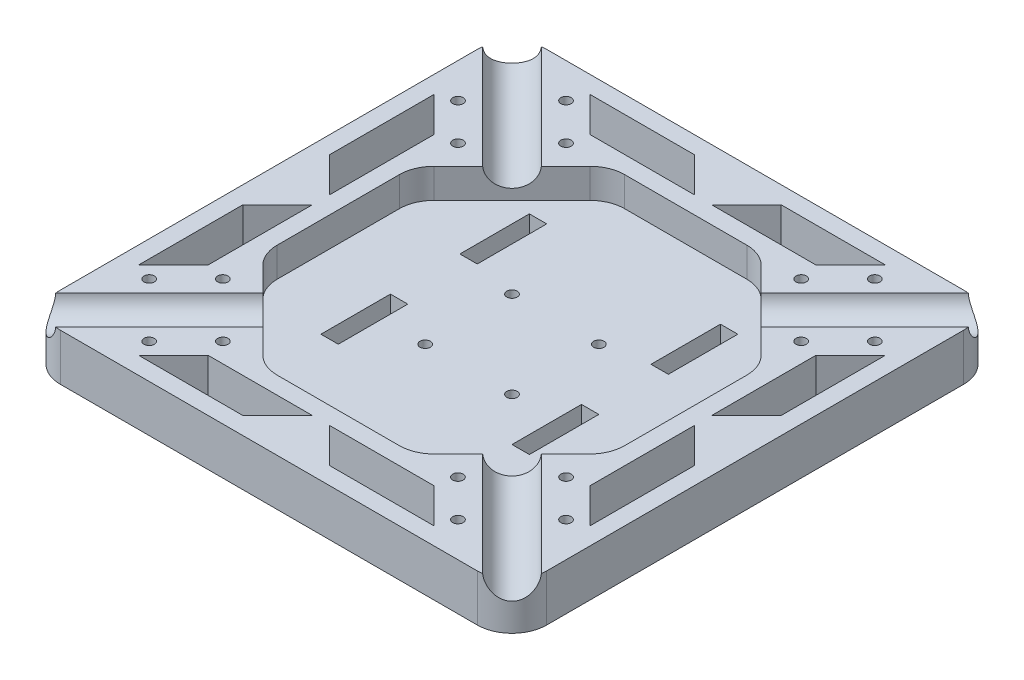
from build123d import *

# Parameters (mm, degrees)
ESQUISSE1_W                  = 140
ESQUISSE1_H                  = 140
ESQUISSE1_W_2                = 5
ESQUISSE1_H_2                = 20
BOSS_EXTRU_1_DEPTH           = 13.5
ENL_V_MAT_EXTRU_3_DEPTH      = 8.5
ENL_V_MAT_EXTRU_1_DEPTH      = 100
R_P_TITION_CIRCULAIRE1_COUNT = 2
R_P_TITION_CIRCULAIRE1_ANGLE = 90
CONG_1_R                     = 10
ESQUISSE3_R                  = 1.5
ENL_V_MAT_EXTRU_2_DEPTH      = 13.5


with BuildPart() as part:
    # Esquisse1 → Boss.-Extru.1 (new body)
    with BuildSketch(Plane(origin=(0, 0, 0), x_dir=(1, 0, 0), z_dir=(0, 1, 0))):
        Rectangle(ESQUISSE1_W, ESQUISSE1_H)
        with Locations((-27.5, 25)):
            Rectangle(ESQUISSE1_W_2, ESQUISSE1_H_2, mode=Mode.SUBTRACT)
        Polygon((65, 12.5), (55, 2.5), (55, 32.5), (65, 42.5), align=None, mode=Mode.SUBTRACT)
        Polygon((65, -12.5), (55, -2.5), (55, -32.5), (65, -42.5), align=None, mode=Mode.SUBTRACT)
        Polygon((12.5, -65), (2.5, -55), (32.5, -55), (42.5, -65), align=None, mode=Mode.SUBTRACT)
        Polygon((-12.5, -65), (-2.5, -55), (-32.5, -55), (-42.5, -65), align=None, mode=Mode.SUBTRACT)
        Polygon((-65, -12.5), (-55, -2.5), (-55, -32.5), (-65, -42.5), align=None, mode=Mode.SUBTRACT)
        Polygon((-65, 12.5), (-55, 2.5), (-55, 32.5), (-65, 42.5), align=None, mode=Mode.SUBTRACT)
        Polygon((-12.5, 65), (-2.5, 55), (-32.5, 55), (-42.5, 65), align=None, mode=Mode.SUBTRACT)
        Polygon((12.5, 65), (2.5, 55), (32.5, 55), (42.5, 65), align=None, mode=Mode.SUBTRACT)
        with Locations((-27.5, -15)):
            Rectangle(ESQUISSE1_W_2, ESQUISSE1_H_2, mode=Mode.SUBTRACT)
        with Locations((27.5, 25)):
            Rectangle(ESQUISSE1_W_2, ESQUISSE1_H_2, mode=Mode.SUBTRACT)
        with Locations((27.5, -15)):
            Rectangle(ESQUISSE1_W_2, ESQUISSE1_H_2, mode=Mode.SUBTRACT)
    extrude(amount=BOSS_EXTRU_1_DEPTH)

    # Esquisse4 → Enlèv. mat.-Extru.3 (cut)
    with BuildSketch(Plane(origin=(0, 13.5, 0), x_dir=(1, 0, 0), z_dir=(0, 1, 0))):
        Polygon((-21.715728753, -50), (21.715728753, -50), (50, -21.715728753), (50, 21.715728753), (21.715728753, 50), (-21.715728753, 50), (-50, 21.715728753), (-50, -21.715728753), align=None)
    extrude(amount=-ENL_V_MAT_EXTRU_3_DEPTH, mode=Mode.SUBTRACT)

    # Esquisse2 → Enlèv. mat.-Extru.1 (cut, symmetric)
    with BuildSketch(Plane(origin=(0, 0, 0), x_dir=(0.7071067811865475, 0, -0.7071067811865477), z_dir=(0.7071067811865477, 0, 0.7071067811865475))):
        with BuildLine():
            Line((-6, 14), (6, 14))
            ThreePointArc((6, 14), (0, 8), (-6, 14))
        make_face()
    enl_v_mat_extru_1 = extrude(amount=ENL_V_MAT_EXTRU_1_DEPTH, both=True, mode=Mode.SUBTRACT)

    # Répétition circulaire1: Enlèv. mat.-Extru.1 ×2 about axis
    r_p_tition_circulaire1_axis = Axis((0, -76.187687151, 0), (0, 1, 0))
    for i in range(1, R_P_TITION_CIRCULAIRE1_COUNT):
        add(enl_v_mat_extru_1.rotate(r_p_tition_circulaire1_axis, i * R_P_TITION_CIRCULAIRE1_ANGLE / (R_P_TITION_CIRCULAIRE1_COUNT - 1)), mode=Mode.SUBTRACT)

    # Congé1
    cong_1_edges = [part.edges().sort_by_distance(p)[0] for p in [
        (-70, 4, -70),
        (-70, 4, 70),
        (70, 4, -70),
        (70, 4, 70),
        (21.715728753, 9.25, -50),
        (50, 9.25, -21.715728753),
        (50, 9.25, 21.715728753),
        (21.715728753, 9.25, 50),
        (-21.715728753, 9.25, 50),
        (-50, 9.25, 21.715728753),
        (-21.715728753, 9.25, -50),
        (-50, 9.25, -21.715728753),
    ]]
    fillet(cong_1_edges, radius=CONG_1_R)

    # Esquisse3 → Enlèv. mat.-Extru.2 (cut)
    with BuildSketch(Plane(origin=(0, 13.5, 0), x_dir=(-1, 0, 0), z_dir=(0, 1, 0))):
        with Locations((44.443650814, 60)):
            Circle(ESQUISSE3_R)
        with Locations((60, 44.443650814)):
            Circle(ESQUISSE3_R)
        with Locations((60, -44.443650814)):
            Circle(ESQUISSE3_R)
        with Locations((44.443650814, -60)):
            Circle(ESQUISSE3_R)
        with Locations((-44.443650814, -60)):
            Circle(ESQUISSE3_R)
        with Locations((-60, -44.443650814)):
            Circle(ESQUISSE3_R)
        with Locations((-60, 44.443650814)):
            Circle(ESQUISSE3_R)
        with Locations((-44.443650814, 60)):
            Circle(ESQUISSE3_R)
        with Locations((49.393398282, 33.837049096)):
            Circle(ESQUISSE3_R)
        with Locations((33.837049096, 49.393398282)):
            Circle(ESQUISSE3_R)
        with Locations((33.837049096, -49.393398282)):
            Circle(ESQUISSE3_R)
        with Locations((49.393398282, -33.837049096)):
            Circle(ESQUISSE3_R)
        with Locations((-49.393398282, -33.837049096)):
            Circle(ESQUISSE3_R)
        with Locations((-33.837049096, -49.393398282)):
            Circle(ESQUISSE3_R)
        with Locations((-33.837049096, 49.393398282)):
            Circle(ESQUISSE3_R)
        with Locations((-49.393398282, 33.837049096)):
            Circle(ESQUISSE3_R)
        with Locations((12.5, -12.5)):
            Circle(ESQUISSE3_R)
        with Locations((-12.5, -12.5)):
            Circle(ESQUISSE3_R)
        with Locations((-12.5, 12.5)):
            Circle(ESQUISSE3_R)
        with Locations((12.5, 12.5)):
            Circle(ESQUISSE3_R)
    extrude(amount=-ENL_V_MAT_EXTRU_2_DEPTH, mode=Mode.SUBTRACT)


solid = part.part
